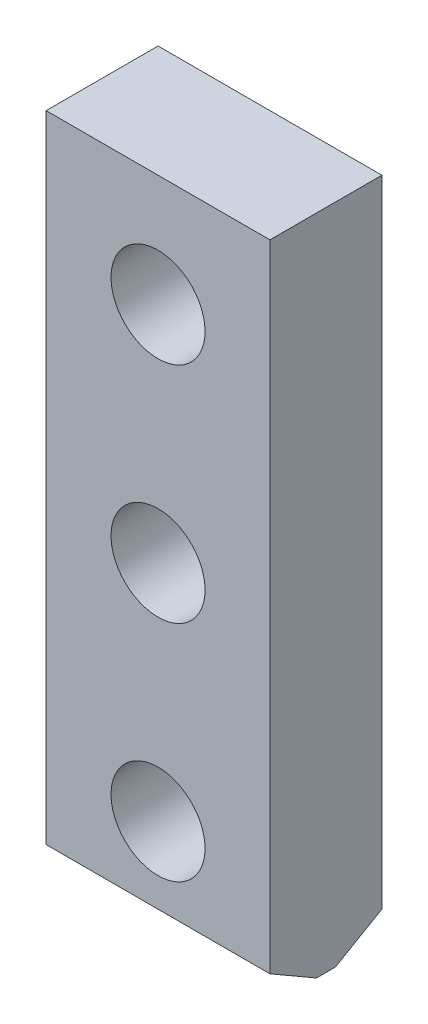
from build123d import *

# Parameters (mm, degrees)
SKETCH_1_W          = 50
SKETCH_1_H          = 148
EXTRUDE_1_DEPTH     = 25
SKETCH_2_R          = 10.5
CUT_EXTRUDE_1_DEPTH = 26
CHAMFER_1_SIZE      = 6
CHAMFER_1_SIZE2     = 10.392304845
CHAMFER_2_SIZE      = 6
CHAMFER_2_SIZE2     = 10.392304845


with BuildPart() as part:
    # Эскиз1 → Бобышка-Вытянуть1 (new body)
    with BuildSketch(Plane.XY):
        with Locations((25, 74)):
            Rectangle(SKETCH_1_W, SKETCH_1_H)
    extrude(amount=EXTRUDE_1_DEPTH)

    # Эскиз2 → Вырез-Вытянуть1 (cut, through all)
    with BuildSketch(Plane.XY.offset(25)):
        with Locations((25, 23)):
            Circle(SKETCH_2_R)
        with Locations((25, 73)):
            Circle(SKETCH_2_R)
        with Locations((25, 123)):
            Circle(SKETCH_2_R)
    extrude(amount=-CUT_EXTRUDE_1_DEPTH, mode=Mode.SUBTRACT)

    # Фаска1
    chamfer_1_edges = [part.edges().sort_by_distance(p)[0] for p in [
        (25, 0, 0),
    ]]
    chamfer_1_side = [part.faces().sort_by_distance(p)[0] for p in [
        (25, 1.562177967, 0),
    ]]
    chamfer(chamfer_1_edges, length=CHAMFER_1_SIZE, length2=CHAMFER_1_SIZE2, reference=chamfer_1_side[0])

    # Фаска2
    chamfer_2_edges = [part.edges().sort_by_distance(p)[0] for p in [
        (25, 0, 25),
    ]]
    chamfer_2_side = [part.faces().sort_by_distance(p)[0] for p in [
        (25, 1.562177967, 25),
    ]]
    chamfer(chamfer_2_edges, length=CHAMFER_2_SIZE, length2=CHAMFER_2_SIZE2, reference=chamfer_2_side[0])


solid = part.part
